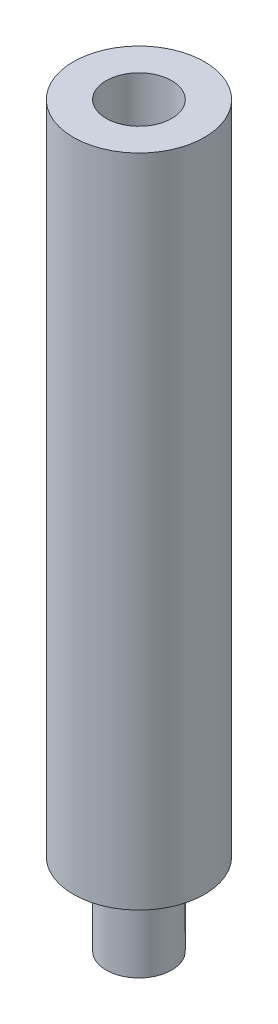
from build123d import *

# Parameters (mm, degrees)
ESQUISSE1_R             = 4
BOSS_EXTRU_1_DEPTH      = 40
ESQUISSE3_R             = 2
ENL_V_MAT_EXTRU_1_DEPTH = 10
ESQUISSE4_R             = 2
BOSS_EXTRU_2_DEPTH      = 5


with BuildPart() as part:
    # Esquisse1 → Boss.-Extru.1 (new body)
    with BuildSketch(Plane(origin=(0, 0, 0), x_dir=(1, 0, 0), z_dir=(0, 1, 0))):
        Circle(ESQUISSE1_R)
    extrude(amount=-BOSS_EXTRU_1_DEPTH)

    # Esquisse3 → Enlèv. mat.-Extru.1 (cut)
    with BuildSketch(Plane(origin=(0, 0, 0), x_dir=(1, 0, 0), z_dir=(0, 1, 0))):
        Circle(ESQUISSE3_R)
    extrude(amount=-ENL_V_MAT_EXTRU_1_DEPTH, mode=Mode.SUBTRACT)

    # Esquisse4 → Boss.-Extru.2 (add)
    with BuildSketch(Plane.XZ.offset(40)):
        Circle(ESQUISSE4_R)
    extrude(amount=BOSS_EXTRU_2_DEPTH)


solid = part.part
